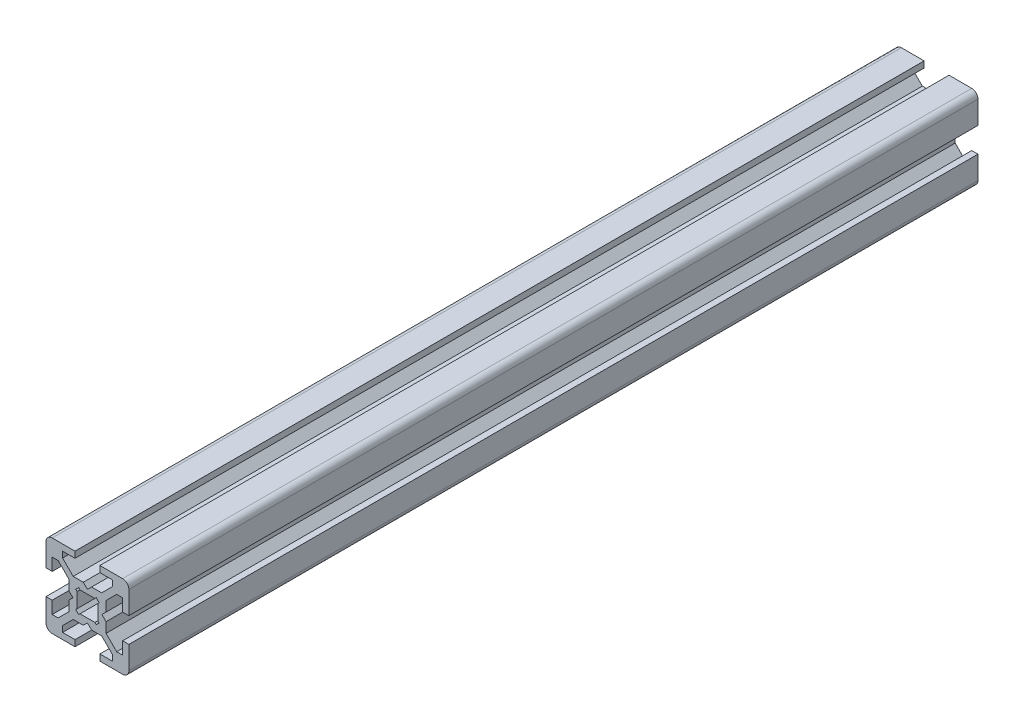
from build123d import *

# Parameters (mm, degrees)
BOSS_EXTRUDE1_DEPTH = 205
FILLET1_R           = 1.5


with BuildPart() as part:
    # Sketch1 → Boss-Extrude1 (new body)
    with BuildSketch(Plane.XY):
        Polygon((0, 3.5), (1, 4.5), (3.439339828, 4.5), (6, 7.060660172), (6, 8.5), (3, 8.5), (3, 10), (10, 10), (10, 3), (8.5, 3), (8.5, 6), (7.060660172, 6), (4.5, 3.439339828), (4.5, 1), (3.5, 0), (4.5, -1), (4.5, -3.439339828), (7.060660172, -6), (8.5, -6), (8.5, -3), (10, -3), (10, -10), (3, -10), (3, -8.5), (6, -8.5), (6, -7.060660172), (3.439339828, -4.5), (1, -4.5), (0, -3.5), (-1, -4.5), (-3.439339828, -4.5), (-6, -7.060660172), (-6, -8.5), (-3, -8.5), (-3, -10), (-10, -10), (-10, -3), (-8.5, -3), (-8.5, -6), (-7.060660172, -6), (-4.5, -3.439339828), (-4.5, -1), (-3.5, 0), (-4.5, 1), (-4.5, 3.439339828), (-7.060660172, 6), (-8.5, 6), (-8.5, 3), (-10, 3), (-10, 10), (-3, 10), (-3, 8.5), (-6, 8.5), (-6, 7.060660172), (-3.439339828, 4.5), (-1, 4.5), align=None)
        Polygon((-1.792893219, 2.5), (1.792893219, 2.5), (2.121320344, 2.828427125), (2.828427125, 2.121320344), (2.5, 1.792893219), (2.5, -1.792893219), (2.828427125, -2.121320344), (2.121320344, -2.828427125), (1.792893219, -2.5), (-1.792893219, -2.5), (-2.121320344, -2.828427125), (-2.828427125, -2.121320344), (-2.5, -1.792893219), (-2.5, 1.792893219), (-2.828427125, 2.121320344), (-2.121320344, 2.828427125), align=None, mode=Mode.SUBTRACT)
    extrude(amount=BOSS_EXTRUDE1_DEPTH)

    # Fillet1
    fillet1_edges = [part.edges().sort_by_distance(p)[0] for p in [
        (10, 10, 102.5),
        (10, -10, 102.5),
        (-10, -10, 102.5),
        (-10, 10, 102.5),
    ]]
    fillet(fillet1_edges, radius=FILLET1_R)


solid = part.part
